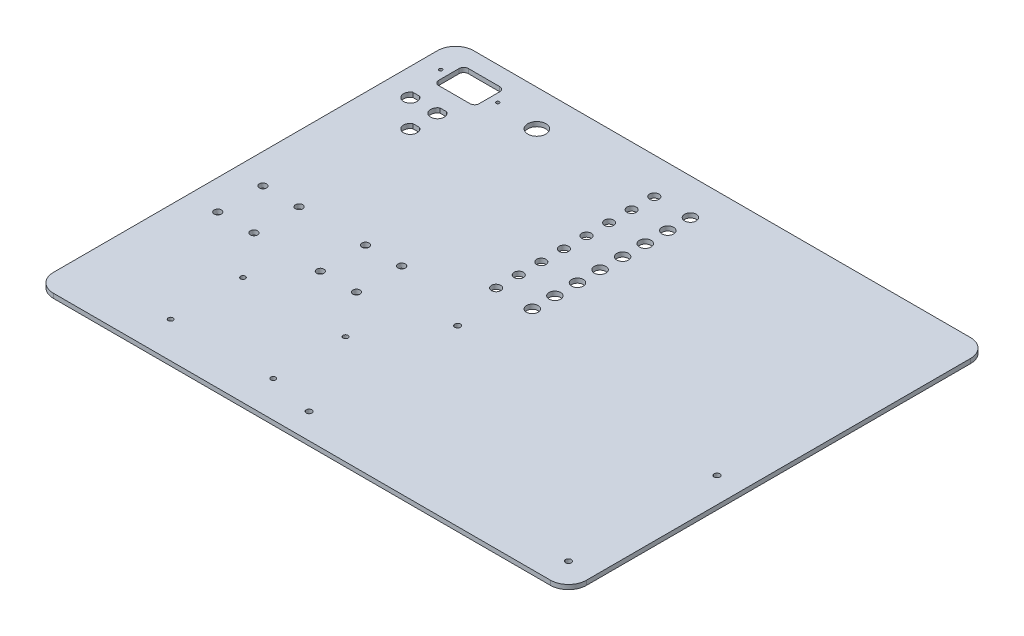
from build123d import *

# Parameters (mm, degrees)
SKETCH1_W              = 374.65
SKETCH1_H              = 295.275
BOSS_EXTRUDE1_DEPTH    = 3.175
FILLET1_R              = 12.7
SKETCH2_R              = 3.2639
SKETCH2_R_2            = 4.1021
CUT_EXTRUDE1_DEPTH     = 4.175
SKETCH3_W              = 28.448
SKETCH3_H              = 20.828
CUT_EXTRUDE2_DEPTH     = 4.175
F_4_40_TAPPED_HOLE1_D  = 2.2606
FILLET2_R              = 3.175
CUT_EXTRUDE3_DEPTH     = 4.175
SKETCH7_R              = 6.35
CUT_EXTRUDE4_DEPTH     = 4.175
F_10_32_TAPPED_HOLE_D  = 4.0386
F_8_32_TAPPED_HOLE1_D  = 3.4544
F_10_CLEARANCE_HOLE2_D = 5.1054


with BuildPart() as part:
    # Sketch1 → Boss-Extrude1 (new body)
    with BuildSketch(Plane(origin=(0, 0, 0), x_dir=(1, 0, 0), z_dir=(0, 1, 0))):
        Rectangle(SKETCH1_W, SKETCH1_H)
    extrude(amount=BOSS_EXTRUDE1_DEPTH)

    # Fillet1
    fillet1_edges = [part.edges().sort_by_distance(p)[0] for p in [
        (187.325, 1.5875, 147.6375),
        (-187.325, 1.5875, 147.6375),
        (-187.325, 1.5875, -147.6375),
        (187.325, 1.5875, -147.6375),
    ]]
    fillet(fillet1_edges, radius=FILLET1_R)

    # Sketch2 → Cut-Extrude1 (cut, through all)
    with BuildSketch(Plane(origin=(0, 3.175, 0), x_dir=(1, 0, 0), z_dir=(0, 1, 0))):
        with Locations((-22.252205122, 122.2375)):
            Circle(SKETCH2_R)
        with Locations((-22.252205122, 106.3625)):
            Circle(SKETCH2_R)
        with Locations((-22.252205122, 90.4875)):
            Circle(SKETCH2_R)
        with Locations((-22.252205122, 74.6125)):
            Circle(SKETCH2_R)
        with Locations((-22.252205122, 58.7375)):
            Circle(SKETCH2_R)
        with Locations((-22.252205122, 42.8625)):
            Circle(SKETCH2_R)
        with Locations((-22.252205122, 26.9875)):
            Circle(SKETCH2_R)
        with Locations((-22.252205122, 11.1125)):
            Circle(SKETCH2_R)
        with Locations((3.147794878, 122.2375)):
            Circle(SKETCH2_R_2)
        with Locations((3.147794878, 106.3625)):
            Circle(SKETCH2_R_2)
        with Locations((3.147794878, 90.4875)):
            Circle(SKETCH2_R_2)
        with Locations((3.147794878, 74.6125)):
            Circle(SKETCH2_R_2)
        with Locations((3.147794878, 58.7375)):
            Circle(SKETCH2_R_2)
        with Locations((3.147794878, 42.8625)):
            Circle(SKETCH2_R_2)
        with Locations((3.147794878, 26.9875)):
            Circle(SKETCH2_R_2)
        with Locations((3.147794878, 11.1125)):
            Circle(SKETCH2_R_2)
    extrude(amount=-CUT_EXTRUDE1_DEPTH, mode=Mode.SUBTRACT)

    # Sketch3 → Cut-Extrude2 (cut, through all)
    with BuildSketch(Plane(origin=(0, 3.175, 0), x_dir=(1, 0, 0), z_dir=(0, 1, 0))):
        with Locations((-154.6225, 124.5235)):
            Rectangle(SKETCH3_W, SKETCH3_H)
    extrude(amount=-CUT_EXTRUDE2_DEPTH, mode=Mode.SUBTRACT)

    # #4-40 Tapped Hole1 (through all)
    with Locations(Plane(origin=(0, 3.175, 0), x_dir=(1, 0, 0), z_dir=(0, 1, 0))):
        with Locations((-174.625, 124.5235), (-134.62, 124.5235)):
            Hole(F_4_40_TAPPED_HOLE1_D / 2)

    # Fillet2
    fillet2_edges = [part.edges().sort_by_distance(p)[0] for p in [
        (-140.3985, 1.5875, -134.9375),
        (-140.3985, 1.5875, -114.1095),
        (-168.8465, 1.5875, -114.1095),
        (-168.8465, 1.5875, -134.9375),
    ]]
    fillet(fillet2_edges, radius=FILLET2_R)

    # Sketch6 → Cut-Extrude3 (cut, through all)
    with BuildSketch(Plane(origin=(0, 3.175, 0), x_dir=(1, 0, 0), z_dir=(0, 1, 0))):
        with BuildLine():
            Line((-170.650952441, 100.965), (-165.899047559, 100.965))
            ThreePointArc((-165.899047559, 100.965), (-168.275, 92.075), (-170.650952441, 100.965))
        make_face()
        with BuildLine():
            Line((-151.600952441, 100.965), (-146.849047559, 100.965))
            ThreePointArc((-146.849047559, 100.965), (-149.225, 92.075), (-151.600952441, 100.965))
        make_face()
        with BuildLine():
            Line((-151.600952441, 81.915), (-146.849047559, 81.915))
            ThreePointArc((-146.849047559, 81.915), (-149.225, 73.025), (-151.600952441, 81.915))
        make_face()
    extrude(amount=-CUT_EXTRUDE3_DEPTH, mode=Mode.SUBTRACT)

    # Sketch7 → Cut-Extrude4 (cut, through all)
    with BuildSketch(Plane(origin=(0, 3.175, 0), x_dir=(1, 0, 0), z_dir=(0, 1, 0))):
        with Locations((-104.775, 122.2375)):
            Circle(SKETCH7_R)
    extrude(amount=-CUT_EXTRUDE4_DEPTH, mode=Mode.SUBTRACT)

    # #10-32 Tapped Hole (through all)
    with Locations(Plane(origin=(0, 3.175, 0), x_dir=(1, 0, 0), z_dir=(0, 1, 0))):
        with Locations((169.422510963, -25.341010963), (-12.847889037, -25.341010963), (-12.847889037, -129.735010963), (169.422510963, -129.735010963)):
            Hole(F_10_32_TAPPED_HOLE_D / 2)

    # #8-32 Tapped Hole1 (through all)
    with Locations(Plane(origin=(0, 3.175, 0), x_dir=(1, 0, 0), z_dir=(0, 1, 0))):
        with Locations((-117.585593705, -122.275595912), (-117.585593705, -71.475595912), (-45.50678376, -71.475595912), (-45.50678376, -122.275595912)):
            Hole(F_8_32_TAPPED_HOLE1_D / 2)

    # #10 Clearance Hole2 (through all)
    with Locations(Plane(origin=(0, 0, 0), x_dir=(-1, 0, 0), z_dir=(0, -1, 0))):
        with Locations((140.925, -8.702499665), (166.325, -8.702499665), (166.325, -40.452499665), (140.925, -40.452499665), (94.246188733, -40.452499665), (94.246188733, -8.702499665), (68.846188733, -8.702499665), (68.846188733, -40.452499665)):
            Hole(F_10_CLEARANCE_HOLE2_D / 2)


solid = part.part
